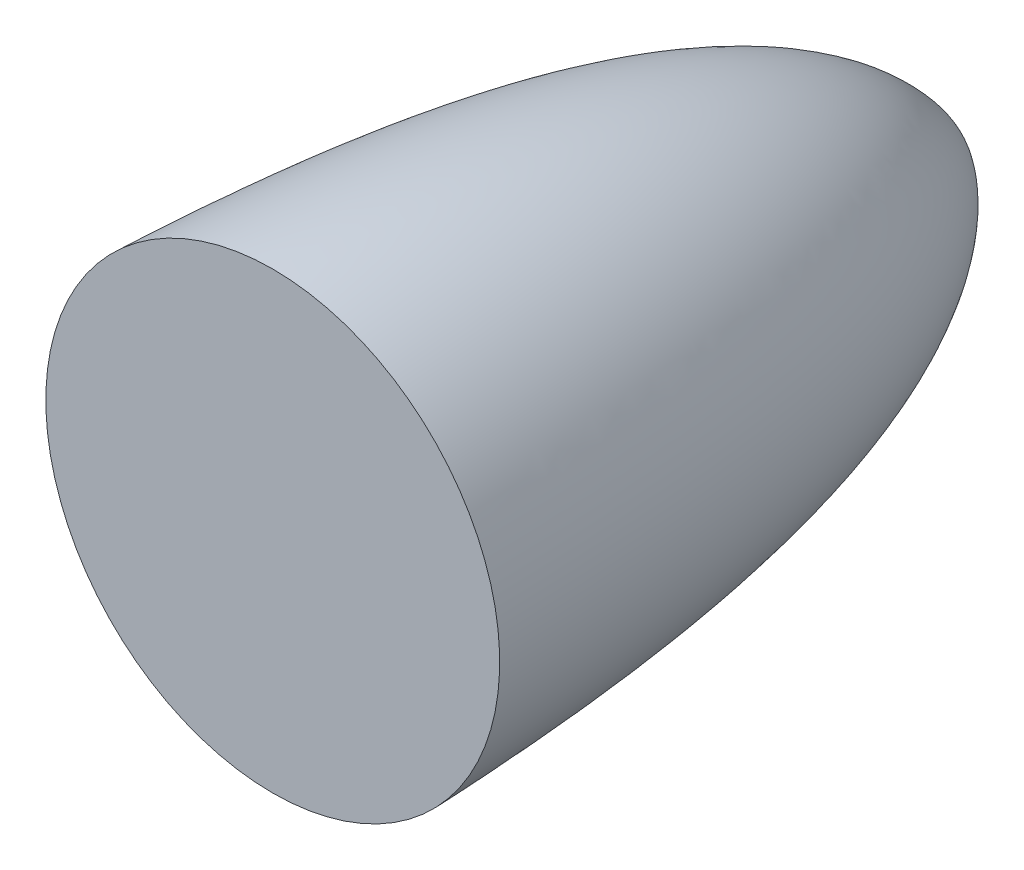
from build123d import *


with BuildPart() as part:
    # Sketch3 → Revolve1 (revolve)
    with BuildSketch(Plane(origin=(0, 0, 0), x_dir=(0, 0, -1), z_dir=(1, 0, 0))):
        with BuildLine():
            Line((0, 10), (0, 0))
            Line((0, 0), (30, 0))
            add(Edge.make_bspline(
                [(0, 10), (14.168320177, 9.473572573), (24.504223595, 7.674602041), (28.789044316, 3.487906986), (30, 0)],
                knots=[0, 0, 0, 0, 0, 1, 1, 1, 1, 1], degree=4))
        make_face()
    revolve(axis=Axis((0, 0, 0), (0, 0, -1)))


solid = part.part
